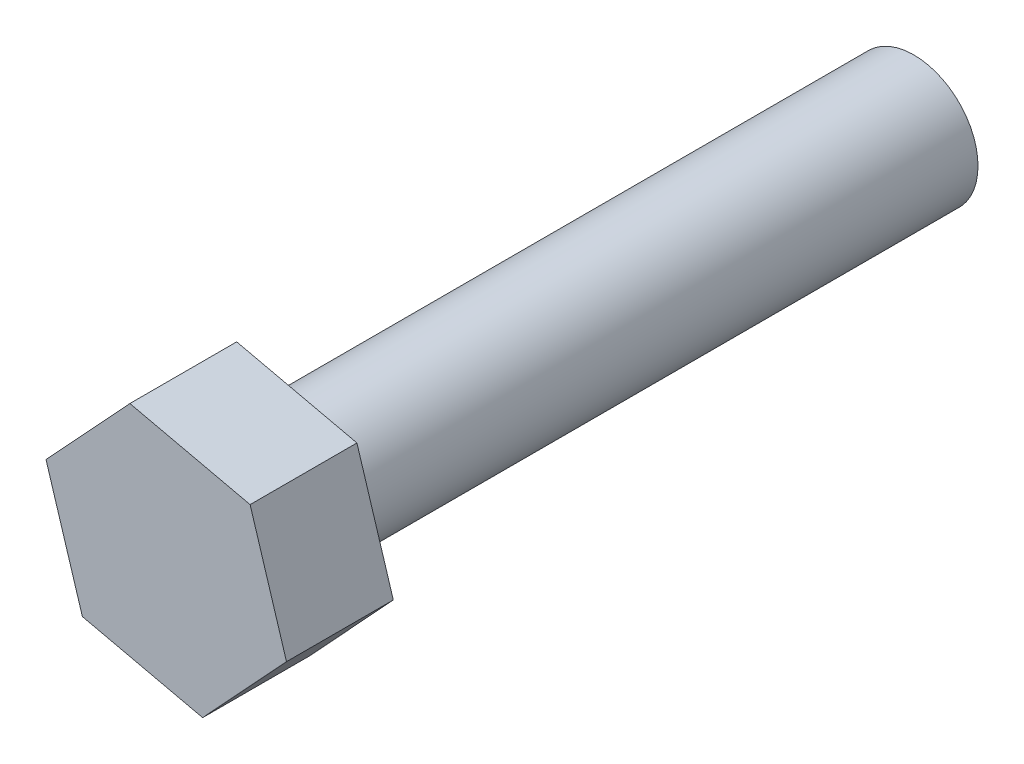
from build123d import *

# Parameters (mm, degrees)
SKETCH_1_R      = 3
EXTRUDE_1_DEPTH = 30
EXTRUDE_2_DEPTH = 5


with BuildPart() as part:
    # 草图1 → 凸台-拉伸1 (new body)
    with BuildSketch(Plane.XY):
        Circle(SKETCH_1_R)
    extrude(amount=EXTRUDE_1_DEPTH)

    # 草图2 → 凸台-拉伸2 (add)
    with BuildSketch(Plane.XY.offset(30)):
        Polygon((3.925938222, 4.233242541), (-1.70312647, 5.516583504), (-5.629064692, 1.283340963), (-3.925938222, -4.233242541), (1.70312647, -5.516583504), (5.629064692, -1.283340963), align=None)
    extrude(amount=EXTRUDE_2_DEPTH)


solid = part.part
